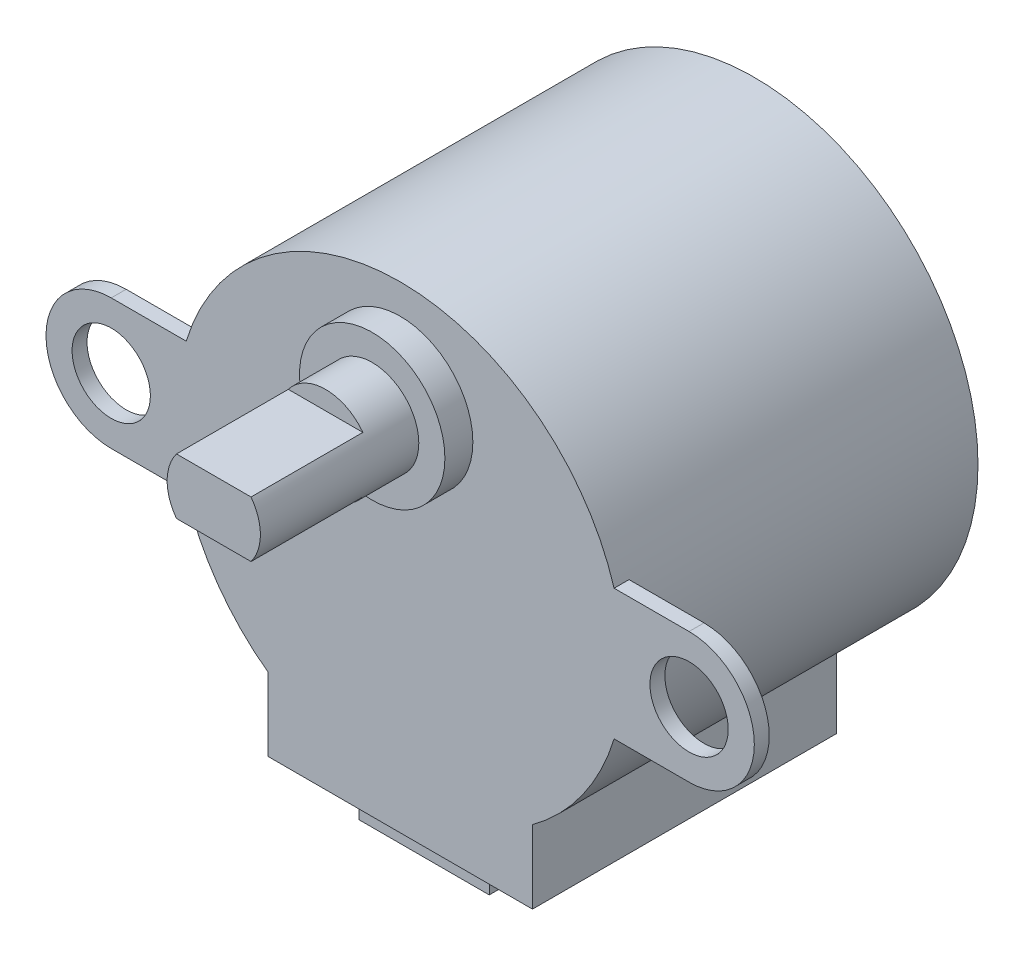
from build123d import *

# Parameters (mm, degrees)
SKETCH1_R           = 12
BOSS_EXTRUDE1_DEPTH = 19
SKETCH2_R           = 3.9
BOSS_EXTRUDE2_DEPTH = 1.5
SKETCH3_R           = 2.1
BOSS_EXTRUDE3_DEPTH = 0.8
SKETCH4_R           = 2.5
BOSS_EXTRUDE4_DEPTH = 8.5
CUT_EXTRUDE2_DEPTH  = 6
SKETCH6_W           = 14.2
SKETCH6_H           = 16.3
BOSS_EXTRUDE5_DEPTH = 13.6
SKETCH7_W           = 7
SKETCH7_H           = 1
BOSS_EXTRUDE6_DEPTH = 2


with BuildPart() as part:
    # Sketch1 → Boss-Extrude1 (new body)
    with BuildSketch(Plane.XY):
        Circle(SKETCH1_R)
    extrude(amount=BOSS_EXTRUDE1_DEPTH)

    # Sketch2 → Boss-Extrude2 (add)
    with BuildSketch(Plane.XY.offset(19)):
        with Locations((0, 6.5)):
            Circle(SKETCH2_R)
    extrude(amount=BOSS_EXTRUDE2_DEPTH)

    # Sketch3 → Boss-Extrude3 (add)
    with BuildSketch(Plane.XY.offset(19)):
        with BuildLine():
            Line((-15.5, 3.5), (15.5, 3.5))
            ThreePointArc((15.5, 3.5), (19, 0), (15.5, -3.5))
            Line((15.5, -3.5), (-15.5, -3.5))
            ThreePointArc((-15.5, -3.5), (-19, 0), (-15.5, 3.5))
        make_face()
        with Locations((-15.5, 0)):
            Circle(SKETCH3_R, mode=Mode.SUBTRACT)
        with Locations((15.5, 0)):
            Circle(SKETCH3_R, mode=Mode.SUBTRACT)
    extrude(amount=-BOSS_EXTRUDE3_DEPTH)

    # Sketch4 → Boss-Extrude4 (add)
    with BuildSketch(Plane.XY.offset(20.5)):
        with Locations((0, 6.5)):
            Circle(SKETCH4_R)
    extrude(amount=BOSS_EXTRUDE4_DEPTH)

    # Sketch5 → Cut-Extrude2 (cut)
    with BuildSketch(Plane.XY.offset(29)):
        with BuildLine():
            Line((-2, 8), (2, 8))
            ThreePointArc((2, 8), (0, 9), (-2, 8))
        make_face()
        with BuildLine():
            Line((2, 5), (-2, 5))
            ThreePointArc((-2, 5), (0, 4), (2, 5))
        make_face()
    extrude(amount=-CUT_EXTRUDE2_DEPTH, mode=Mode.SUBTRACT)

    # Sketch6 → Boss-Extrude5 (add)
    with BuildSketch(Plane(origin=(0, 0, 0), x_dir=(1, 0, 0), z_dir=(0, 1, 0))):
        with Locations((0, -10.85)):
            Rectangle(SKETCH6_W, SKETCH6_H)
    extrude(amount=-BOSS_EXTRUDE5_DEPTH)

    # Sketch7 → Boss-Extrude6 (add)
    with BuildSketch(Plane.XZ.offset(13.6)):
        with Locations((-0.219512042, 17)):
            Rectangle(SKETCH7_W, SKETCH7_H)
    extrude(amount=BOSS_EXTRUDE6_DEPTH)


solid = part.part
